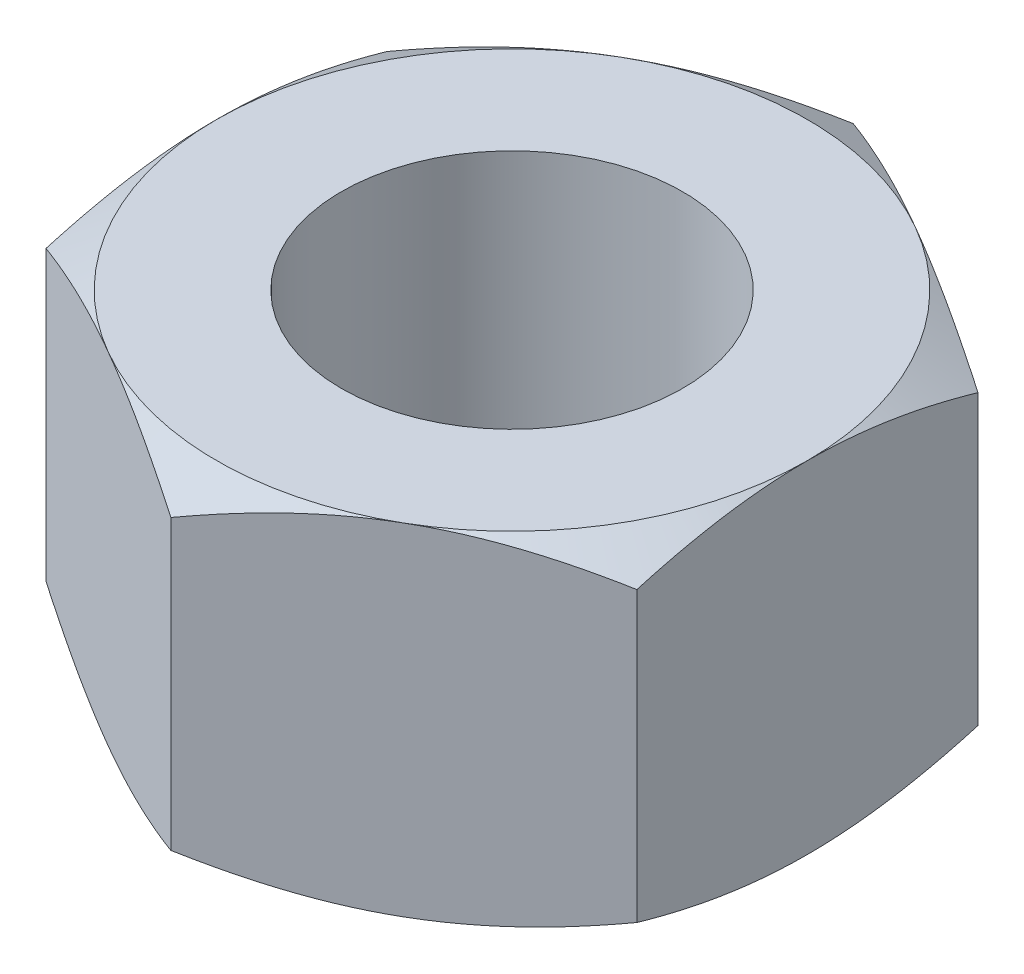
from build123d import *

# Parameters (mm, degrees)
SKETCH1_R                    = 4.5
BOSS_EXTRUDE1_DEPTH          = 9
SKETCH2_OUTSIDE_W            = 29.608
SKETCH2_OUTSIDE_H            = 32.02
SKETCH2_OUTSIDE_R            = 7.794228634
CUT_EXTRUDE3_DEPTH           = 1
CUT_EXTRUDE3_TAPER           = 60
CUT_EXTRUDE3_OTHER_WAY_DEPTH = 1
CUT_EXTRUDE3_OTHER_WAY_TAPER = 60


with BuildPart() as part:
    # Sketch1 → Boss-Extrude1 (new body)
    with BuildSketch(Plane(origin=(0, 0, 0), x_dir=(1, 0, 0), z_dir=(0, 1, 0))):
        Polygon((7.794228634, 4.5), (0, 9), (-7.794228634, 4.5), (-7.794228634, -4.5), (0, -9), (7.794228634, -4.5), align=None)
        with Locations(Location((0, 0, 0), (0, 0, 270))):  # turned: the seam where the file's is
            Circle(SKETCH1_R, mode=Mode.SUBTRACT)
    extrude(amount=BOSS_EXTRUDE1_DEPTH)

    # Sketch2 outside → Cut-Extrude3 (cut)
    with BuildSketch(Plane(origin=(0, 0, 0), x_dir=(1, 0, 0), z_dir=(0, 1, 0))):
        Rectangle(SKETCH2_OUTSIDE_W, SKETCH2_OUTSIDE_H)
        Circle(SKETCH2_OUTSIDE_R, mode=Mode.SUBTRACT)
    cut_extrude3 = extrude(amount=CUT_EXTRUDE3_DEPTH, taper=CUT_EXTRUDE3_TAPER, mode=Mode.SUBTRACT)

    # Sketch2 outside → Cut-Extrude3 other way (cut)
    with BuildSketch(Plane(origin=(0, 0, 0), x_dir=(1, 0, 0), z_dir=(0, 1, 0))):
        Rectangle(SKETCH2_OUTSIDE_W, SKETCH2_OUTSIDE_H)
        Circle(SKETCH2_OUTSIDE_R, mode=Mode.SUBTRACT)
    extrude(amount=-CUT_EXTRUDE3_OTHER_WAY_DEPTH, taper=CUT_EXTRUDE3_OTHER_WAY_TAPER, mode=Mode.SUBTRACT)

    # Mirror2: Cut-Extrude3 across plane
    add(cut_extrude3.mirror(Plane.ZX.offset(4.5)), mode=Mode.SUBTRACT)


solid = part.part
